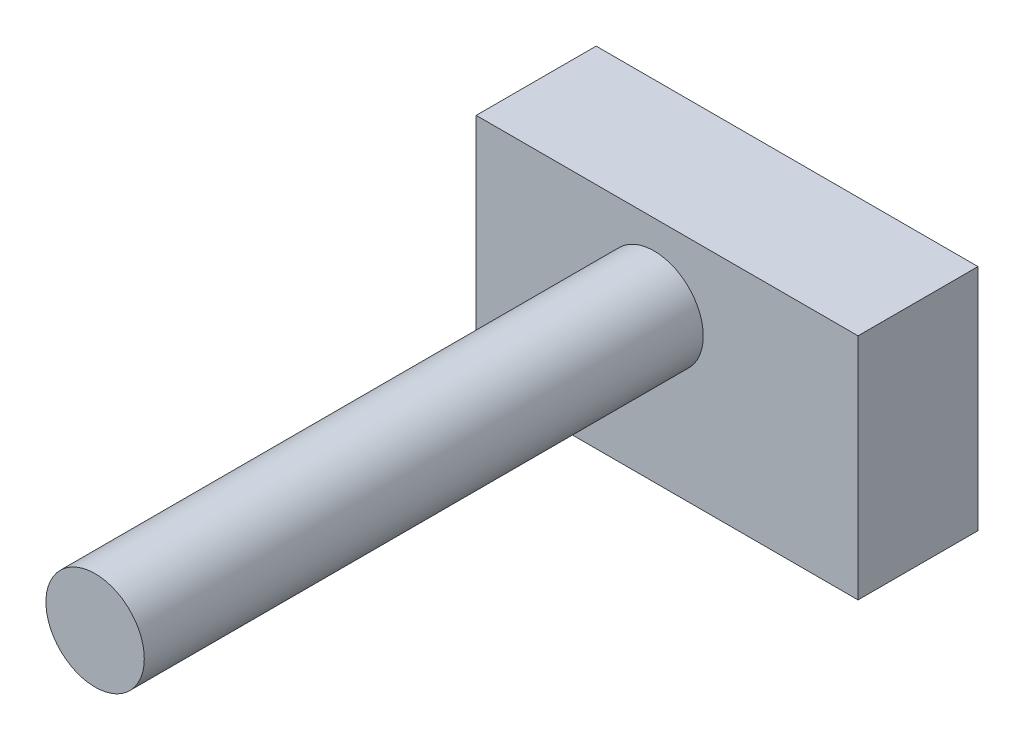
from build123d import *

# Parameters (mm, degrees)
SKETCH1_W           = 161.724310644
SKETCH1_H           = 96.872862076
BOSS_EXTRUDE1_DEPTH = 50.8
SKETCH2_R           = 20.831004362
BOSS_EXTRUDE2_DEPTH = 236.728


with BuildPart() as part:
    # Sketch1 → Boss-Extrude1 (new body)
    with BuildSketch(Plane.XY):
        Rectangle(SKETCH1_W, SKETCH1_H)
    extrude(amount=BOSS_EXTRUDE1_DEPTH)

    # Sketch2 → Boss-Extrude2 (add)
    with BuildSketch(Plane.XY.offset(50.8)):
        with Locations((-5.525694513, 15.560482637)):
            Circle(SKETCH2_R)
    extrude(amount=BOSS_EXTRUDE2_DEPTH)


solid = part.part
